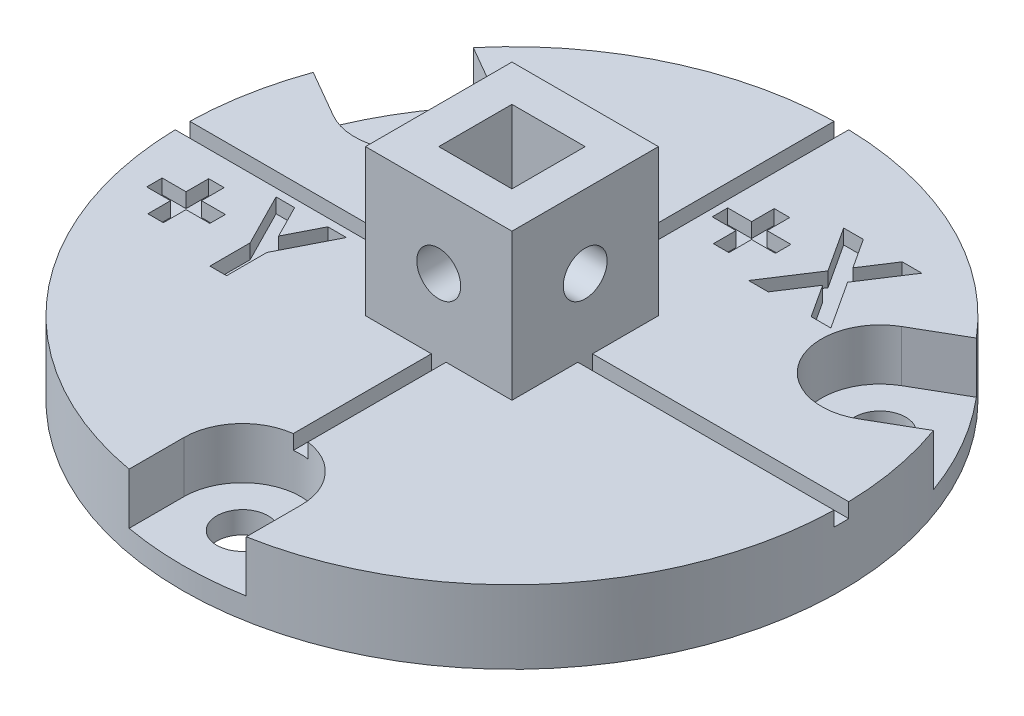
from build123d import *

# Parameters (mm, degrees)
SKETCH1_R                     = 22.5
PLATE_DEPTH                   = 5
OPENING_START                 = 1.5
OPENING_FOR_SCREW_DEPTH       = 5
SKETCH7_R                     = 1.75
SCREW_HOLE_DEPTH              = 5
CIRPATTERN20_COUNT            = 3
SKETCH10_W                    = 45
SKETCH10_H                    = 1
SKETCH10_W_2                  = 1
SKETCH10_H_2                  = 45
CUT_EXTRUDE5_DEPTH            = 1
CUT_EXTRUDE6_DEPTH            = 1
SKETCH12_W                    = 10
SKETCH12_H                    = 10
SKETCH12_W_2                  = 5
SKETCH12_H_2                  = 5
TOOL_CONNECT_PIECE_DEPTH      = 10
TOOL_CONNECT_PIECE_DEPTH_BACK = 1
SKETCH14_R                    = 1.5
CUT_EXTRUDE8_DEPTH            = 10
SKETCH15_R                    = 1.5
CUT_EXTRUDE9_DEPTH            = 28.5


with BuildPart() as part:
    # Sketch1 → plate (new body)
    with BuildSketch(Plane(origin=(0, 0, 0), x_dir=(1, 0, 0), z_dir=(0, 1, 0))):
        Circle(SKETCH1_R)
    extrude(amount=PLATE_DEPTH)

    # Sketch6 → opening for screw (cut)
    with BuildSketch(Plane(origin=(0, 5, 0), x_dir=(1, 0, 0), z_dir=(0, 1, 0)).offset(OPENING_START)):
        with BuildLine():
            Line((-4, -22.5), (-4, -18.4))
            ThreePointArc((-4, -18.4), (0, -14.4), (4, -18.4))
            Line((4, -18.4), (4, -22.5))
            ThreePointArc((4, -22.5), (0, -26.5), (-4, -22.5))
        make_face()
    opening_for_screw = extrude(amount=-OPENING_FOR_SCREW_DEPTH, mode=Mode.SUBTRACT)

    # Sketch7 → screw hole (cut)
    with BuildSketch(Plane(origin=(0, 1.5, 0), x_dir=(1, 0, 0), z_dir=(0, 1, 0))):
        with Locations((0, -18.4)):
            Circle(SKETCH7_R)
    screw_hole = extrude(amount=-SCREW_HOLE_DEPTH, mode=Mode.SUBTRACT)

    # CirPattern20: opening for screw, screw hole ×3 about axis
    cirpattern20_axis = Axis((0, 0, 0), (0, 1, 0))
    for i in range(1, CIRPATTERN20_COUNT):
        add(opening_for_screw.rotate(cirpattern20_axis, i * 360 / CIRPATTERN20_COUNT), mode=Mode.SUBTRACT)
        add(screw_hole.rotate(cirpattern20_axis, i * 360 / CIRPATTERN20_COUNT), mode=Mode.SUBTRACT)

    # Sketch10 → Cut-Extrude5 (cut)
    with BuildSketch(Plane(origin=(0, 5, 0), x_dir=(1, 0, 0), z_dir=(0, 1, 0))):
        Rectangle(SKETCH10_W, SKETCH10_H)
        Rectangle(SKETCH10_W_2, SKETCH10_H_2)
    extrude(amount=-CUT_EXTRUDE5_DEPTH, mode=Mode.SUBTRACT)

    # Sketch11 → Cut-Extrude6 (cut)
    with BuildSketch(Plane(origin=(0, 5, 0), x_dir=(1, 0, 0), z_dir=(0, 1, 0))):
        Polygon((2.616666667, 13.742425761), (2.616666667, 15.289220632), (3.675, 15.289220632), (3.675, 13.742425761), (5.303205128, 13.742425761), (5.303205128, 12.684092427), (3.675, 12.684092427), (3.675, 11.137297556), (2.616666667, 11.137297556), (2.616666667, 12.684092427), (0.988461538, 12.684092427), (0.988461538, 13.742425761), align=None)
        Polygon((6.136388221, 16.510374479), (7.479657452, 16.510374479), (8.806390224, 14.471301963), (10.135667067, 16.510374479), (11.480208333, 16.510374479), (9.47802484, 13.43968137), (11.6125, 10.160374479), (10.269230769, 10.160374479), (8.806390224, 12.409332812), (7.339733574, 10.160374479), (5.995192308, 10.160374479), (8.134755609, 13.440953405), align=None)
        Polygon((-18.458103671, -3.794817635), (-18.458103671, -2.248022763), (-17.399770338, -2.248022763), (-17.399770338, -3.794817635), (-15.771565209, -3.794817635), (-15.771565209, -4.853150968), (-17.399770338, -4.853150968), (-17.399770338, -6.39994584), (-18.458103671, -6.39994584), (-18.458103671, -4.853150968), (-20.086308799, -4.853150968), (-20.086308799, -3.794817635), align=None)
        Polygon((-15.07957803, -1.026868917), (-13.811358879, -1.026868917), (-12.677975466, -3.254202651), (-11.544592052, -1.026868917), (-10.276372902, -1.026868917), (-12.108103671, -4.626728693), (-12.108103671, -7.376868917), (-13.247847261, -7.376868917), (-13.247847261, -4.626728693), align=None)
    extrude(amount=-CUT_EXTRUDE6_DEPTH, mode=Mode.SUBTRACT)

    # Sketch12 → tool connect piece (add, two sides)
    with BuildSketch(Plane(origin=(0, 5, 0), x_dir=(1, 0, 0), z_dir=(0, 1, 0))) as tool_connect_piece_sk:
        Rectangle(SKETCH12_W, SKETCH12_H)
        Rectangle(SKETCH12_W_2, SKETCH12_H_2, mode=Mode.SUBTRACT)
    extrude(amount=TOOL_CONNECT_PIECE_DEPTH)
    extrude(tool_connect_piece_sk.sketch, amount=-TOOL_CONNECT_PIECE_DEPTH_BACK)

    # Sketch14 → Cut-Extrude8 (cut)
    with BuildSketch(Plane(origin=(0, 0, -5), x_dir=(-1, 0, 0), z_dir=(0, 0, -1))):
        with Locations((0, 10)):
            Circle(SKETCH14_R)
    extrude(amount=-CUT_EXTRUDE8_DEPTH, mode=Mode.SUBTRACT)

    # Sketch15 → Cut-Extrude9 (cut, through all)
    with BuildSketch(Plane(origin=(5, 0, 0), x_dir=(0, 0, -1), z_dir=(1, 0, 0))):
        with Locations((0, 10)):
            Circle(SKETCH15_R)
    extrude(amount=-CUT_EXTRUDE9_DEPTH, mode=Mode.SUBTRACT)


solid = part.part
